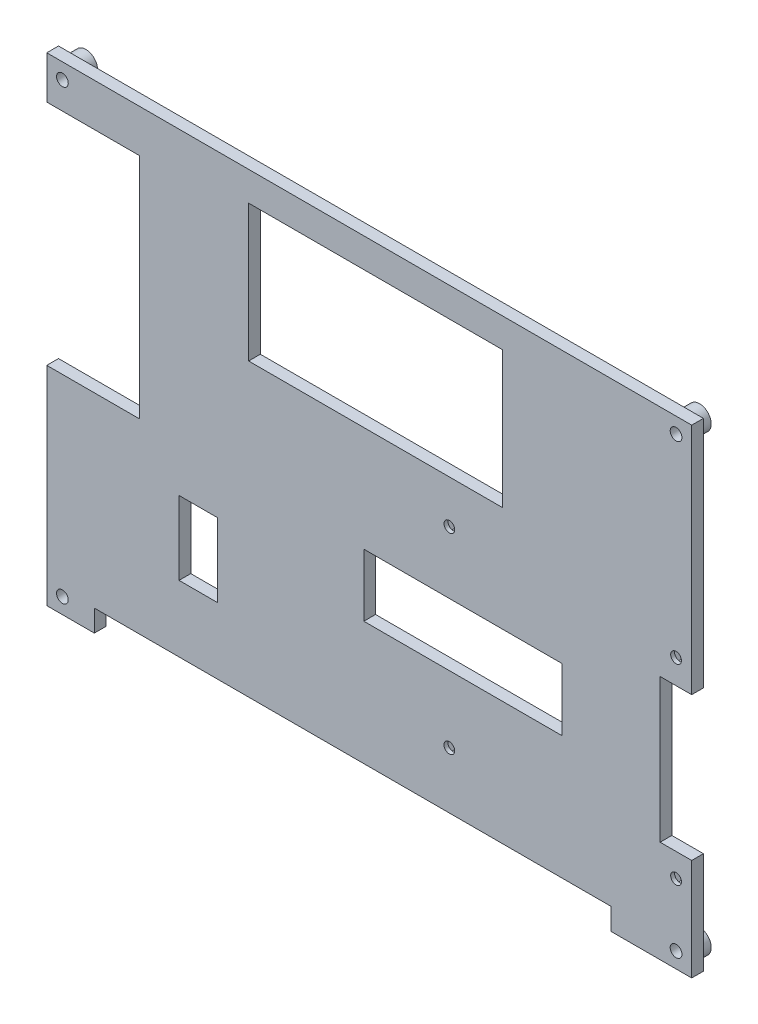
from build123d import *

# Parameters (mm, degrees)
CROQUIS9_W              = 165
CROQUIS9_H              = 122.5
CROQUIS9_R              = 1.5
SALIENTE_EXTRUIR7_DEPTH = 3
CROQUIS10_R             = 3
CROQUIS10_R_2           = 1.5
SALIENTE_EXTRUIR4_DEPTH = 3
CROQUIS13_R             = 1.375
CORTAR_EXTRUIR6_DEPTH   = 7
CORTAR_EXTRUIR9_DEPTH   = 2
CROQUIS19_W             = 23.751706854
CROQUIS19_H             = 58.322995046
CORTAR_EXTRUIR11_DEPTH  = 7
CROQUIS20_W             = 8.074798139
CROQUIS20_H             = 36.716786424
CORTAR_EXTRUIR12_DEPTH  = 7
CROQUIS21_W             = 132.215541909
CROQUIS21_H             = 5.552865293
CORTAR_EXTRUIR13_DEPTH  = 7
CROQUIS22_W             = 64.97984938
CROQUIS22_H             = 34.980531845
CORTAR_EXTRUIR14_DEPTH  = 10
CROQUIS23_W             = 9.785151637
CROQUIS23_H             = 18.811760375
CORTAR_EXTRUIR15_DEPTH  = 7
CROQUIS24_W             = 50.724588702
CROQUIS24_H             = 15.98003992
CORTAR_EXTRUIR16_DEPTH  = 10


with BuildPart() as part:
    # Croquis9 → Saliente-Extruir7 (new body)
    with BuildSketch(Plane(origin=(0, -39.711212197, 0), x_dir=(-1, 0, 0), z_dir=(0, 0, 1))):
        with Locations((0, -39.711212197)):
            Rectangle(CROQUIS9_W, CROQUIS9_H)
        with Locations((-78.5, 17.538787803)):
            Circle(CROQUIS9_R, mode=Mode.SUBTRACT)
        with Locations((78.5, 17.538787803)):
            Circle(CROQUIS9_R, mode=Mode.SUBTRACT)
        with Locations((-78.5, -96.961212197)):
            Circle(CROQUIS9_R, mode=Mode.SUBTRACT)
        with Locations((78.5, -96.961212197)):
            Circle(CROQUIS9_R, mode=Mode.SUBTRACT)
    extrude(amount=SALIENTE_EXTRUIR7_DEPTH)

    # Croquis10 → Saliente-Extruir4 (add)
    with BuildSketch(Plane(origin=(0, -39.711212197, 0), x_dir=(1, 0, 0), z_dir=(0, 0, -1))):
        with Locations((-78.5, 18.288787803)):
            Circle(CROQUIS10_R)
        with Locations((-78.5, 18.288787803)):
            Circle(CROQUIS10_R_2, mode=Mode.SUBTRACT)
        with Locations((78.5, 18.288787803)):
            Circle(CROQUIS10_R)
        with Locations((78.5, 18.288787803)):
            Circle(CROQUIS10_R_2, mode=Mode.SUBTRACT)
        with Locations((78.5, -97.711212197)):
            Circle(CROQUIS10_R)
        with Locations((78.5, -97.711212197)):
            Circle(CROQUIS10_R_2, mode=Mode.SUBTRACT)
        with Locations((-78.5, -97.711212197)):
            Circle(CROQUIS10_R)
        with Locations((-78.5, -97.711212197)):
            Circle(CROQUIS10_R_2, mode=Mode.SUBTRACT)
    extrude(amount=SALIENTE_EXTRUIR4_DEPTH)

    # Croquis13 → Cortar-Extruir6 (cut, through all)
    with BuildSketch(Plane(origin=(0, -58.652466741, 3), x_dir=(1, 0, 0), z_dir=(0, 0, -1))):
        with Locations((20.5, -17.402466741)):
            Circle(CROQUIS13_R)
        with Locations((78.5, -17.402466741)):
            Circle(CROQUIS13_R)
        with Locations((20.5, -66.402466741)):
            Circle(CROQUIS13_R)
        with Locations((78.5, -66.402466741)):
            Circle(CROQUIS13_R)
    extrude(amount=CORTAR_EXTRUIR6_DEPTH, mode=Mode.SUBTRACT)

    # Croquis17 → Cortar-Extruir9 (cut)
    with BuildSketch(Plane(origin=(0, -39.711212197, 0), x_dir=(1, 0, 0), z_dir=(0, 0, -1))):
        Polygon((23.340563324, 1.538787803), (21.920281662, 3.998787803), (19.079718338, 3.998787803), (17.659436676, 1.538787803), (19.079718338, -0.921212197), (21.920281662, -0.921212197), align=None)
        Polygon((81.340563324, 1.538787803), (79.920281662, 3.998787803), (77.079718338, 3.998787803), (75.659436676, 1.538787803), (77.079718338, -0.921212197), (79.920281662, -0.921212197), align=None)
        Polygon((81.340563324, -47.461212197), (79.920281662, -45.001212197), (77.079718338, -45.001212197), (75.659436676, -47.461212197), (77.079718338, -49.921212197), (79.920281662, -49.921212197), align=None)
        Polygon((23.340563324, -47.461212197), (21.920281662, -45.001212197), (19.079718338, -45.001212197), (17.659436676, -47.461212197), (19.079718338, -49.921212197), (21.920281662, -49.921212197), align=None)
    extrude(amount=-CORTAR_EXTRUIR9_DEPTH, mode=Mode.SUBTRACT)

    # Croquis19 → Cortar-Extruir11 (cut, through all)
    with BuildSketch(Plane.XY.offset(3)):
        with Locations((-70.624146573, 21.159042343)):
            Rectangle(CROQUIS19_W, CROQUIS19_H)
    extrude(amount=-CORTAR_EXTRUIR11_DEPTH, mode=Mode.SUBTRACT)

    # Croquis20 → Cortar-Extruir12 (cut, through all)
    with BuildSketch(Plane.XY.offset(3)):
        with Locations((78.462600931, -16.844106748)):
            Rectangle(CROQUIS20_W, CROQUIS20_H)
    extrude(amount=-CORTAR_EXTRUIR12_DEPTH, mode=Mode.SUBTRACT)

    # Croquis21 → Cortar-Extruir13 (cut, through all)
    with BuildSketch(Plane.XY.offset(3)):
        with Locations((-4.222973471, -58.473567354)):
            Rectangle(CROQUIS21_W, CROQUIS21_H)
    extrude(amount=-CORTAR_EXTRUIR13_DEPTH, mode=Mode.SUBTRACT)

    # Croquis22 → Cortar-Extruir14 (cut)
    with BuildSketch(Plane.XY.offset(3)):
        with Locations((1.632848722, 36.266393101)):
            Rectangle(CROQUIS22_W, CROQUIS22_H)
    extrude(amount=-CORTAR_EXTRUIR14_DEPTH, mode=Mode.SUBTRACT)

    # Croquis23 → Cortar-Extruir15 (cut, through all)
    with BuildSketch(Plane.XY.offset(3)):
        with Locations((-43.761194105, -29.321605041)):
            Rectangle(CROQUIS23_W, CROQUIS23_H)
    extrude(amount=-CORTAR_EXTRUIR15_DEPTH, mode=Mode.SUBTRACT)

    # Croquis24 → Cortar-Extruir16 (cut)
    with BuildSketch(Plane(origin=(0, 0, 0), x_dir=(-1, 0, 0), z_dir=(0, 0, -1))):
        with Locations((-23.977071959, -16.156592187)):
            Rectangle(CROQUIS24_W, CROQUIS24_H)
    extrude(amount=-CORTAR_EXTRUIR16_DEPTH, mode=Mode.SUBTRACT)


solid = part.part
